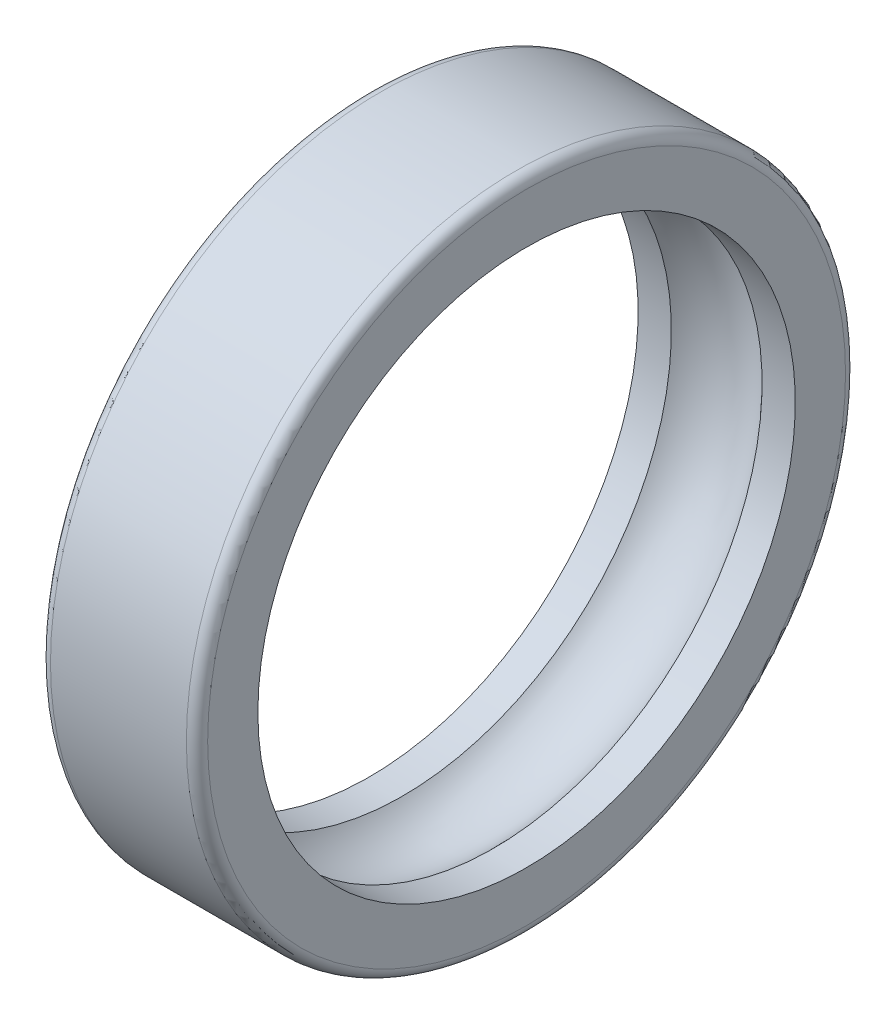
from build123d import *

# Parameters (mm, degrees)
FILLET1_R = 2.1


with BuildPart() as part:
    # Sketch1 → Revolve1 (revolve)
    with BuildSketch(Plane.XY):
        with BuildLine():
            Line((-15.5, 65), (15.5, 65))
            Line((15.5, 65), (15.5, 53))
            Line((15.5, 53), (8.94427191, 53))
            ThreePointArc((8.94427191, 53), (0, 57), (-8.94427191, 53))
            Line((-8.94427191, 53), (-15.5, 53))
            Line((-15.5, 53), (-15.5, 65))
        make_face()
    revolve(axis=Axis((-9.392847635, 0, 0), (1, 0, 0)))

    # Fillet1
    fillet1_edges = [part.edges().sort_by_distance(p)[0] for p in [
        (15.5, -65, 0),
        (-15.5, -65, 0),
    ]]
    fillet(fillet1_edges, radius=FILLET1_R)


solid = part.part
